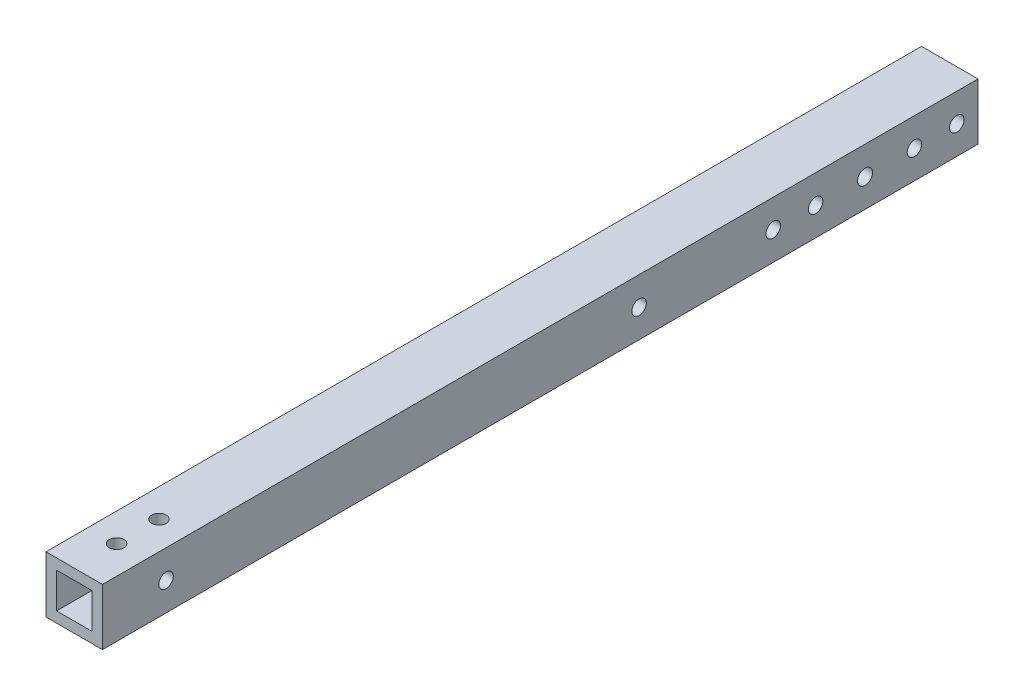
from build123d import *

# Parameters (mm, degrees)
SKETCH4_W                        = 25.4
SKETCH4_H                        = 25.4
SKETCH4_W_2                      = 15.875
SKETCH4_H_2                      = 15.875
BOSS_EXTRUDE1_DEPTH              = 196.85
F_0_257_DIAMETER_HOLE1_D         = 6.5278
F_0_257_DIAMETER_HOLE2_D         = 6.5278
F_0_257_DIAMETER_HOLE3_D         = 6.5278
F_17_64_0_26563_DIAMETER_HOLE1_D = 6.747002


with BuildPart() as part:
    # Sketch4 → Boss-Extrude1 (new body, symmetric)
    with BuildSketch(Plane.XY):
        Rectangle(SKETCH4_W, SKETCH4_H)
        Rectangle(SKETCH4_W_2, SKETCH4_H_2, mode=Mode.SUBTRACT)
    extrude(amount=BOSS_EXTRUDE1_DEPTH, both=True)

    # F (0.257) Diameter Hole1 (through all)
    with Locations(Plane.ZY.offset(12.7)):
        with Locations((-104.775, 0), (-123.825, 0), (-168.275, 0), (-187.325, 0)):
            Hole(F_0_257_DIAMETER_HOLE1_D / 2)

    # F (0.257) Diameter Hole2 (through all)
    with Locations(Plane(origin=(0, 12.7, 0), x_dir=(1, 0, 0), z_dir=(0, 1, 0))):
        with Locations((0, -177.8), (0, -158.75)):
            Hole(F_0_257_DIAMETER_HOLE2_D / 2)

    # F (0.257) Diameter Hole3 (through all)
    with Locations(Plane.ZY.offset(12.7)):
        with Locations((168.275, 0), (-44.45, 0)):
            Hole(F_0_257_DIAMETER_HOLE3_D / 2)

    # 17/64 (0.26563) Diameter Hole1 (through all)
    with Locations(Plane.ZY.offset(12.7)):
        with Locations((-146.05, 0)):
            Hole(F_17_64_0_26563_DIAMETER_HOLE1_D / 2)


solid = part.part
